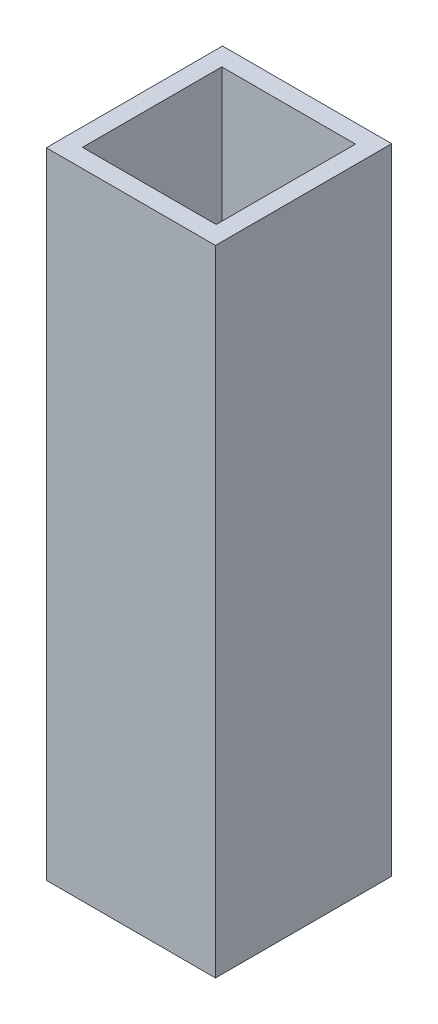
from build123d import *

# Parameters (mm, degrees)
SKETCH1_W           = 12
SKETCH1_H           = 12.5
SKETCH1_W_2         = 9.483200932
SKETCH1_H_2         = 9.878334304
BOSS_EXTRUDE1_DEPTH = 45
SKETCH1_2_W         = 9.483200932
SKETCH1_2_H         = 9.878334304
BOSS_EXTRUDE2_DEPTH = 2


with BuildPart() as part:
    # Sketch1 → Boss-Extrude1 (new body)
    with BuildSketch(Plane(origin=(0, 0, 0), x_dir=(1, 0, 0), z_dir=(0, 1, 0))):
        Rectangle(SKETCH1_W, SKETCH1_H)
        Rectangle(SKETCH1_W_2, SKETCH1_H_2, mode=Mode.SUBTRACT)
    extrude(amount=BOSS_EXTRUDE1_DEPTH)

    # Sketch1_2 → Boss-Extrude2 (add)
    with BuildSketch(Plane(origin=(0, 0, 0), x_dir=(1, 0, 0), z_dir=(0, 1, 0))):
        Rectangle(SKETCH1_2_W, SKETCH1_2_H)
    extrude(amount=BOSS_EXTRUDE2_DEPTH)


solid = part.part
